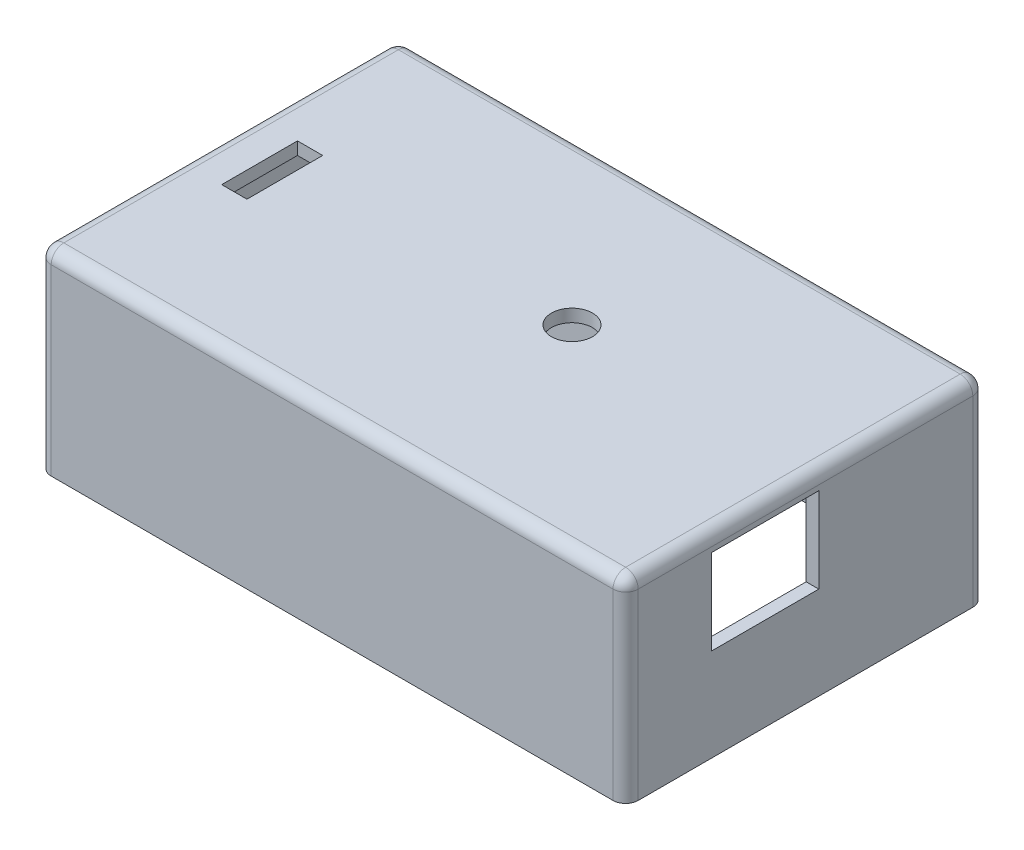
from build123d import *

# Parameters (mm, degrees)
SKETCH1_W           = 93
SKETCH1_H           = 57
BOSS_EXTRUDE1_DEPTH = 31
SHELL1_T            = -2
SKETCH2_W           = 17
SKETCH2_H           = 13.5
CUT_EXTRUDE1_DEPTH  = 2
SKETCH3_R           = 3.25
CUT_EXTRUDE2_DEPTH  = 2
SKETCH4_W           = 4
SKETCH4_H           = 12
CUT_EXTRUDE3_DEPTH  = 2
SKETCH5_R           = 3
SKETCH5_R_2         = 3.25
CUT_EXTRUDE4_DEPTH  = 2
SKETCH6_R           = 5
CUT_EXTRUDE5_DEPTH  = 2
FILLET1_R           = 2
SKETCH7_W           = 91.2
SKETCH7_H           = 55.2
SKETCH7_W_2         = 89
SKETCH7_H_2         = 53
CUT_EXTRUDE6_DEPTH  = 1.1
SKETCH8_W           = 10
SKETCH8_H           = 10
BOSS_EXTRUDE2_DEPTH = 5


with BuildPart() as part:
    # Sketch1 → Boss-Extrude1 (new body)
    with BuildSketch(Plane(origin=(0, 0, 0), x_dir=(1, 0, 0), z_dir=(0, 1, 0))):
        Rectangle(SKETCH1_W, SKETCH1_H)
    extrude(amount=BOSS_EXTRUDE1_DEPTH)

    # Shell1
    shell1_openings = [part.faces().sort_by_distance(p)[0] for p in [
        (0, 0, 0),
    ]]
    offset(amount=SHELL1_T, openings=shell1_openings, kind=Kind.INTERSECTION)

    # Sketch2 → Cut-Extrude1 (cut)
    with BuildSketch(Plane(origin=(46.5, 0, 0), x_dir=(0, 0, -1), z_dir=(1, 0, 0))):
        with Locations((-6.4, 21.45)):
            Rectangle(SKETCH2_W, SKETCH2_H)
    extrude(amount=-CUT_EXTRUDE1_DEPTH, mode=Mode.SUBTRACT)

    # Sketch3 → Cut-Extrude2 (cut)
    with BuildSketch(Plane(origin=(0, 31, 0), x_dir=(1, 0, 0), z_dir=(0, 1, 0))):
        with Locations((7, 2.5)):
            Circle(SKETCH3_R)
    extrude(amount=-CUT_EXTRUDE2_DEPTH, mode=Mode.SUBTRACT)

    # Sketch4 → Cut-Extrude3 (cut)
    with BuildSketch(Plane(origin=(0, 31, 0), x_dir=(1, 0, 0), z_dir=(0, 1, 0))):
        with Locations((-37.987270606, 0)):
            Rectangle(SKETCH4_W, SKETCH4_H)
    extrude(amount=-CUT_EXTRUDE3_DEPTH, mode=Mode.SUBTRACT)

    # Sketch5 → Cut-Extrude4 (cut)
    with BuildSketch(Plane(origin=(0, 0, -28.5), x_dir=(-1, 0, 0), z_dir=(0, 0, -1))):
        with Locations((31.5, 15.5)):
            Circle(SKETCH5_R)
        with Locations((16.5, 15.5)):
            Circle(SKETCH5_R_2)
    extrude(amount=-CUT_EXTRUDE4_DEPTH, mode=Mode.SUBTRACT)

    # Sketch6 → Cut-Extrude5 (cut)
    with BuildSketch(Plane.ZY.offset(46.5)):
        with Locations((-18.5, 15.5)):
            Circle(SKETCH6_R)
    extrude(amount=-CUT_EXTRUDE5_DEPTH, mode=Mode.SUBTRACT)

    # Fillet1
    fillet1_edges = [part.edges().sort_by_distance(p)[0] for p in [
        (-46.5, 31, 0),
        (0, 31, 28.5),
        (46.5, 31, 0),
        (46.5, 15.5, 28.5),
        (-46.5, 15.5, 28.5),
        (-46.5, 15.5, -28.5),
        (46.5, 15.5, -28.5),
        (0, 31, -28.5),
    ]]
    fillet(fillet1_edges, radius=FILLET1_R)

    # Sketch7 → Cut-Extrude6 (cut)
    with BuildSketch(Plane.XZ):
        Rectangle(SKETCH7_W, SKETCH7_H)
        Rectangle(SKETCH7_W_2, SKETCH7_H_2, mode=Mode.SUBTRACT)
    extrude(amount=-CUT_EXTRUDE6_DEPTH, mode=Mode.SUBTRACT)

    # Sketch8 → Boss-Extrude2 (add)
    with BuildSketch(Plane(origin=(0, 1.7, 0), x_dir=(-1, 0, 0), z_dir=(0, -1, 0))):
        with Locations((-39.5, 21.5)):
            Rectangle(SKETCH8_W, SKETCH8_H)
        with Locations((-39.5, -21.5)):
            Rectangle(SKETCH8_W, SKETCH8_H)
        with Locations((39.5, -21.5)):
            Rectangle(SKETCH8_W, SKETCH8_H)
        with Locations((39.5, 21.5)):
            Rectangle(SKETCH8_W, SKETCH8_H)
    extrude(amount=-BOSS_EXTRUDE2_DEPTH)


solid = part.part
